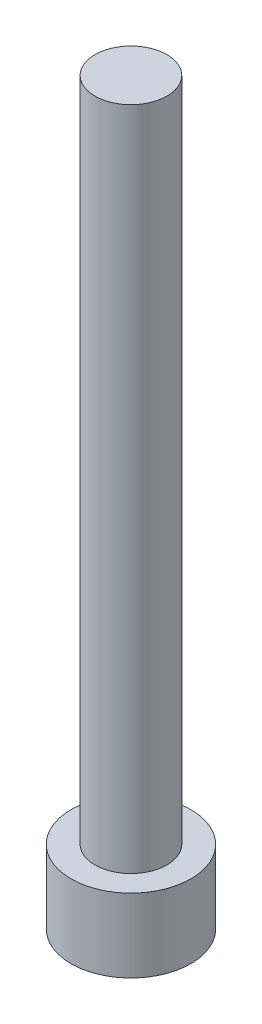
from build123d import *

# Parameters (mm, degrees)
SKETCH1_R           = 2.8575
BOSS_EXTRUDE1_DEPTH = 3.5052
CUT_EXTRUDE1_DEPTH  = 1.9558
SKETCH3_R           = 1.7145
BOSS_EXTRUDE2_DEPTH = 31.75


with BuildPart() as part:
    # Sketch1 → Boss-Extrude1 (new body)
    with BuildSketch(Plane(origin=(0, 0, 0), x_dir=(1, 0, 0), z_dir=(0, 1, 0))):
        Circle(SKETCH1_R)
    extrude(amount=BOSS_EXTRUDE1_DEPTH)

    # Sketch2 → Cut-Extrude1 (cut)
    with BuildSketch(Plane.XZ):
        Polygon((1.603951217, 0), (0.801975608, 1.3890625), (-0.801975608, 1.3890625), (-1.603951217, 0), (-0.801975608, -1.3890625), (0.801975608, -1.3890625), align=None)
    extrude(amount=-CUT_EXTRUDE1_DEPTH, mode=Mode.SUBTRACT)

    # Sketch3 → Boss-Extrude2 (add)
    with BuildSketch(Plane(origin=(0, 3.5052, 0), x_dir=(1, 0, 0), z_dir=(0, 1, 0))):
        Circle(SKETCH3_R)
    extrude(amount=BOSS_EXTRUDE2_DEPTH)


solid = part.part
